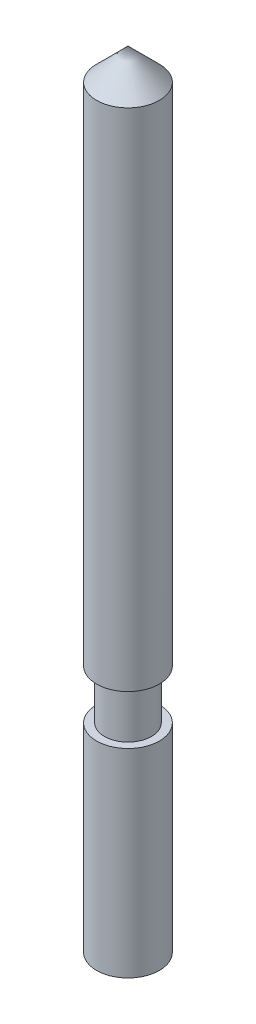
from build123d import *


with BuildPart() as part:
    # Эскиз1 → Повернуть1 (revolve)
    with BuildSketch(Plane.XY):
        Polygon((0, 14.639707177), (-1, 13.639707177), (-1, -2.460292823), (-0.75, -2.460292823), (-0.75, -4.030292823), (-1, -4.030292823), (-1, -10.360292823), (0, -10.360292823), align=None)
    revolve(axis=Axis((0, 20.732586553, 0), (0, -1, 0)))


solid = part.part
